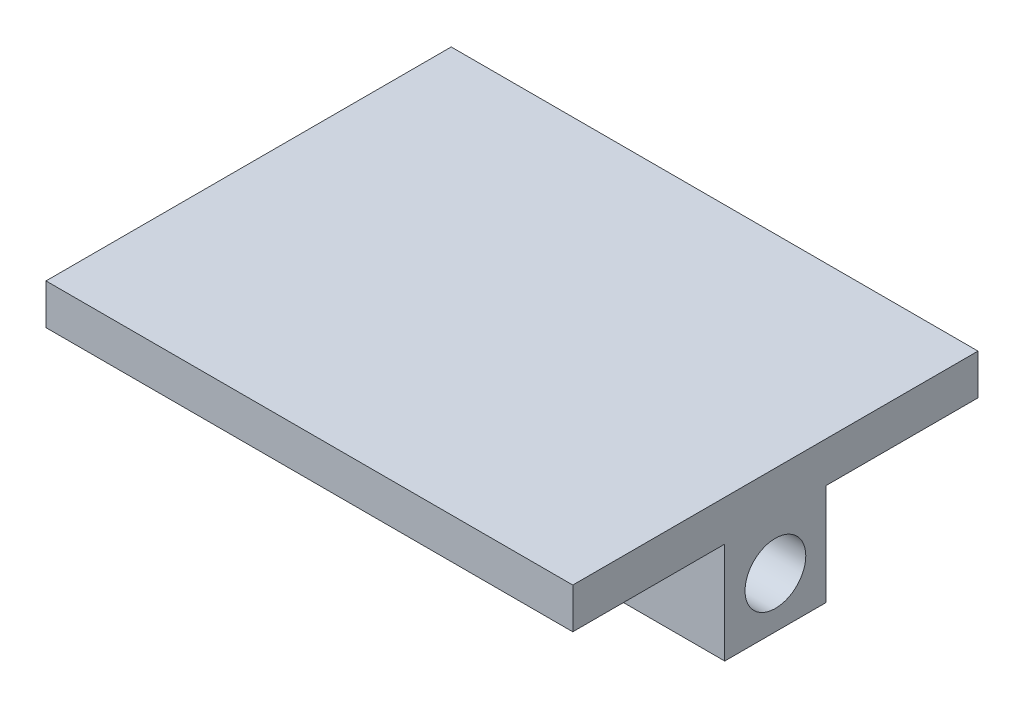
from build123d import *

# Parameters (mm, degrees)
SKETCH1_W           = 165.1
SKETCH1_H           = 127
BOSS_EXTRUDE1_DEPTH = 6.35
SKETCH2_W           = 165.1
SKETCH2_H           = 31.75
BOSS_EXTRUDE2_DEPTH = 31.75
CUT_EXTRUDE1_REACH  = 167.1
SKETCH3_R           = 9.525


with BuildPart() as part:
    # Sketch1 → Boss-Extrude1 (new body, symmetric)
    with BuildSketch(Plane(origin=(0, 0, 0), x_dir=(1, 0, 0), z_dir=(0, 1, 0))):
        Rectangle(SKETCH1_W, SKETCH1_H)
    extrude(amount=BOSS_EXTRUDE1_DEPTH, both=True)

    # Sketch2 → Boss-Extrude2 (add)
    with BuildSketch(Plane.XZ.offset(6.35)):
        Rectangle(SKETCH2_W, SKETCH2_H)
    extrude(amount=BOSS_EXTRUDE2_DEPTH)

    # Sketch3 → Cut-Extrude1 (cut, up to next)
    with BuildSketch(Plane(origin=(82.55, 0, 0), x_dir=(0, 0, -1), z_dir=(1, 0, 0)), mode=Mode.PRIVATE) as cut_extrude1_sk1:
        with Locations((0, -22.225)):
            Circle(SKETCH3_R)
    cut_extrude1_tool1 = extrude(cut_extrude1_sk1.sketch, amount=-CUT_EXTRUDE1_REACH, mode=Mode.PRIVATE) & part.part
    add(cut_extrude1_tool1.solids().sort_by_distance((82.55, -22.225, 0))[0], mode=Mode.SUBTRACT)


solid = part.part
